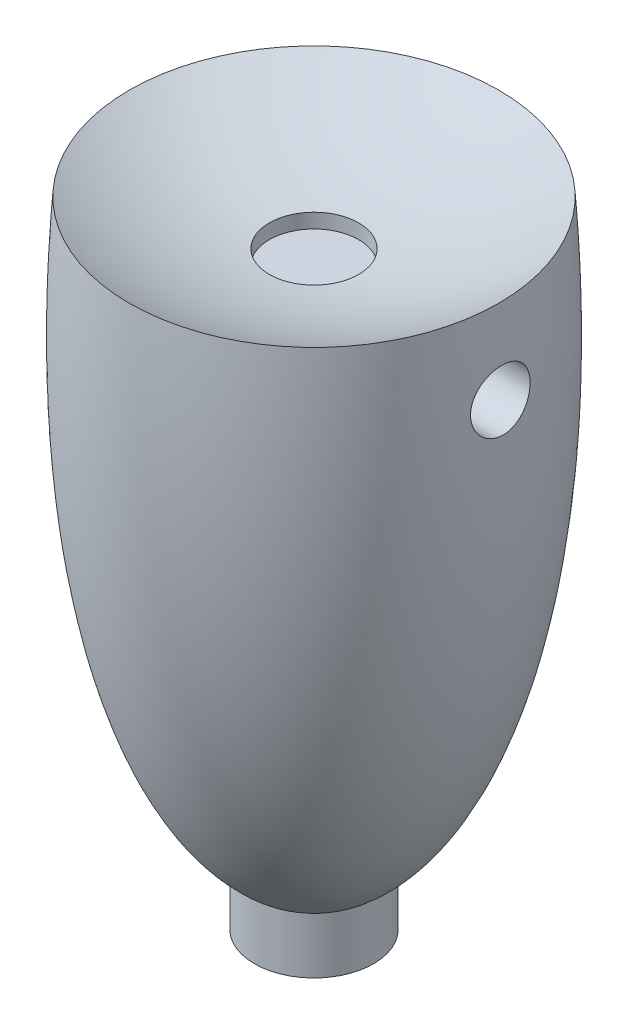
from build123d import *

# Parameters (mm, degrees)
DOME2_FACE_RADIUS               = 3.1
DOME2_HEIGHT                    = 0.8
SKETCH6_R                       = 0.500000006
CUT_EXTRUDE2_DEPTH              = 1
SKETCH7_R                       = 0.75
CUT_EXTRUDE3_DEPTH              = 1
BOSS_EXTRUDE1_REACH             = 12.152
SKETCH9_R                       = 1
SKETCH9_R_2                     = 0.45
BOSS_EXTRUDE1_DIRECTION_2_DEPTH = 0.5
SCALE1_SCALE                    = 2


with BuildPart() as part:
    # Sketch2 → Revolve2 (revolve)
    with BuildSketch(Plane.XY):
        with BuildLine():
            Line((0, 0), (3.1, 0))
            add(Edge.make_bspline(
                [(0, -10.151978408), (2.177642547, -9.857333884), (3.515065362, -5.793498011), (3.1, 0)],
                knots=[0, 0, 0, 0, 1, 1, 1, 1], degree=3))
            Line((0, -10.151978408), (0, 0))
        make_face()
    revolve(axis=Axis((0, -10.151978408, 0), (0, 1, 0)))

    # Dome2: a dome of height H over a round flat face of radius A is a cap of a sphere of radius (A * A + H * H) / (2 * H)
    dome2_r = (DOME2_FACE_RADIUS * DOME2_FACE_RADIUS + DOME2_HEIGHT * DOME2_HEIGHT) / (2 * DOME2_HEIGHT)
    dome2_base = Plane((0, 0, 0), z_dir=(0, -1, 0))
    with Locations(dome2_base.offset(DOME2_HEIGHT - dome2_r)):
        dome2_ball = Sphere(dome2_r, mode=Mode.PRIVATE)
    add(split(dome2_ball, bisect_by=dome2_base, keep=Keep.TOP, mode=Mode.PRIVATE), mode=Mode.SUBTRACT)

    # Sketch6 → Cut-Extrude2 (cut, symmetric)
    with BuildSketch(Plane(origin=(3.16696636, 0, 0), x_dir=(0, 0, -1), z_dir=(1, 0, 0))):
        with Locations((0, -1.377313707)):
            Circle(SKETCH6_R)
    cut_extrude2 = extrude(amount=CUT_EXTRUDE2_DEPTH, both=True, mode=Mode.SUBTRACT)

    # Mirror1: Cut-Extrude2 across plane
    add(cut_extrude2.mirror(Plane(origin=(0, 0, 0), x_dir=(0, 0, 1), z_dir=(1, 0, 0))), mode=Mode.SUBTRACT)

    # Sketch7 → Cut-Extrude3 (cut)
    with BuildSketch(Plane(origin=(0, 0, 0), x_dir=(1, 0, 0), z_dir=(0, 1, 0))):
        Circle(SKETCH7_R)
    extrude(amount=-CUT_EXTRUDE3_DEPTH, mode=Mode.SUBTRACT)

    # Sketch9 → Boss-Extrude1 (add, up to next)
    with BuildSketch(Plane(origin=(0, -10.151978408, 0), x_dir=(1, 0, 0), z_dir=(0, 1, 0)), mode=Mode.PRIVATE) as boss_extrude1_sk1:
        Circle(SKETCH9_R)
        Circle(SKETCH9_R_2, mode=Mode.SUBTRACT)
    boss_extrude1_tool1 = extrude(boss_extrude1_sk1.sketch, amount=BOSS_EXTRUDE1_REACH, mode=Mode.PRIVATE) - part.part
    add(boss_extrude1_tool1.solids().sort_by_distance((-0.971716, -10.151978, 0))[0])

    # Sketch9 → Boss-Extrude1 direction 2 (add)
    with BuildSketch(Plane(origin=(0, -10.151978408, 0), x_dir=(1, 0, 0), z_dir=(0, 1, 0))):
        Circle(SKETCH9_R)
        Circle(SKETCH9_R_2, mode=Mode.SUBTRACT)
    extrude(amount=-BOSS_EXTRUDE1_DIRECTION_2_DEPTH)


with BuildPart() as part_1:
    # Scale1: scaled about (3.7e-08, -4.298834834, 9.2e-08)
    add(part.part.scale(SCALE1_SCALE).moved(Location((-3.7e-08, 4.298834834, -9.2e-08))))


solid = part_1.part
